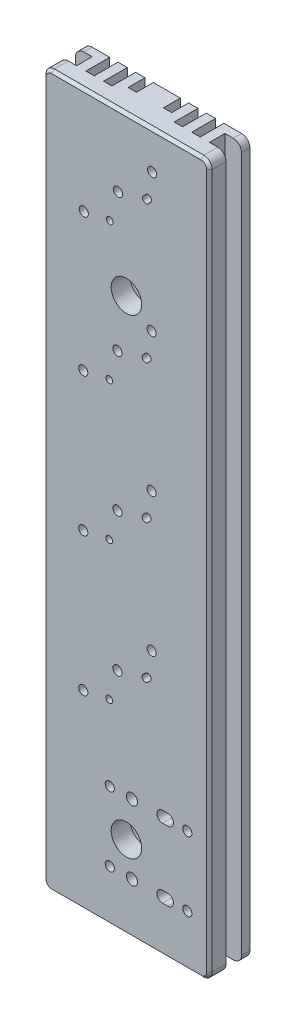
from build123d import *

# Parameters (mm, degrees)
SKETCH_1_W                  = 60
SKETCH_1_H                  = 260
EXTRUDE_1_DEPTH             = 14.6
MM_6_D                      = 2.4
MM_6_DEPTH                  = 5
MM_6_TIP                    = 0.721032743
CUT_EXTRUDE_1_DEPTH         = 5
HOLE_WIZARD_M4_1_D          = 3.3
HOLE_WIZARD_M4_1_DEPTH      = 5
HOLE_WIZARD_M4_1_TIP        = 0.991420021
HOLE_WIZARD_M4_2_AT_2_COUNT = 2
HOLE_WIZARD_M4_2_AT_2_PITCH = 27.999757981
CUT_EXTRUDE_2_DEPTH         = 5
SKETCH_19_W                 = 3
SKETCH_19_H                 = 260
CUT_EXTRUDE_3_DEPTH         = 8.6
PATTERN_LINEAR_2_COUNT      = 9
PATTERN_LINEAR_2_PITCH      = 6.375
FILLET_1_R                  = 1
HOLE_WIZARD_M4_4_D          = 3.3
HOLE_WIZARD_M4_4_DEPTH      = 5
HOLE_WIZARD_M4_4_TIP        = 0.991420021
MM_6_2_D                    = 2.4
MM_6_2_DEPTH                = 5
MM_6_2_TIP                  = 0.721032743
CUT_EXTRUDE_5_DEPTH         = 5
CHAMFER_2_SIZE              = 0.5
SKETCH_36_W                 = 6
SKETCH_36_H                 = 8.6
CUT_EXTRUDE_6_DEPTH         = 261
SKETCH_37_W                 = 6
SKETCH_37_H                 = 3
EXTRUDE_3_DEPTH             = 260
SKETCH_41_W                 = 3
SKETCH_41_H                 = 2.5
EXTRUDE_4_DEPTH             = 260
HOLE_WIZARD_3_D             = 6.6
HOLE_WIZARD_3_CBORE_D       = 11
HOLE_WIZARD_3_CBORE_DEPTH   = 6.8
PATTERN_LINEAR_3_COUNT      = 2
PATTERN_LINEAR_3_PITCH      = 25
MM_6_3_D                    = 4
MM_6_3_DEPTH                = 5
MM_6_3_TIP                  = 1.201721238
SKETCH_45_W                 = 60
SKETCH_45_H                 = 3
CUT_EXTRUDE_7_DEPTH         = 15.6
FILLET_2_R                  = 3
CHAMFER_5_SIZE              = 1
CUT_EXTRUDE_8_DEPTH         = 5


with BuildPart() as part:
    # 草图1 → 凸台-拉伸1 (new body)
    with BuildSketch(Plane.XY):
        with Locations((-1370.803187494, -284.67131833)):
            Rectangle(SKETCH_1_W, SKETCH_1_H)
    extrude(amount=EXTRUDE_1_DEPTH)

    # mm _6
    with Locations(Plane(origin=(-1376.81028397, -194.132502963, 14.6), x_dir=(1, 0, 0), z_dir=(0, 0, 1))):
        with Locations((0, 0)):
            Hole(MM_6_D / 2, depth=MM_6_DEPTH)
            with Locations((0, 0, -(MM_6_DEPTH + MM_6_TIP / 2))):  # 118° drill point
                Cone(0, MM_6_D / 2, MM_6_TIP, mode=Mode.SUBTRACT)

    # 草图13 → 切除-拉伸1 (cut)
    with BuildSketch(Plane.XY.offset(14.6)):
        with BuildLine():
            Line((-1362.067107582, -181.08638285), (-1362.91563572, -181.934910987))
            ThreePointArc((-1362.91563572, -181.934910987), (-1364.612691995, -181.934910987), (-1364.612691995, -180.237854712))
            Line((-1364.612691995, -180.237854712), (-1363.764163857, -179.389326575))
            ThreePointArc((-1363.764163857, -179.389326575), (-1362.067107582, -179.389326575), (-1362.067107582, -181.08638285))
        make_face()
    extrude(amount=-CUT_EXTRUDE_1_DEPTH, mode=Mode.SUBTRACT)

    # M4 螺纹孔1
    with Locations(Plane(origin=(-1386.194651617, -195.973455467, 14.6), x_dir=(1, 0, 0), z_dir=(0, 0, 1))):
        with Locations((0, 0), (12.347852167, 12.347852166), (24.695704333, 24.695704332)):
            Hole(HOLE_WIZARD_M4_1_D / 2, depth=HOLE_WIZARD_M4_1_DEPTH)
            with Locations((0, 0, -(HOLE_WIZARD_M4_1_DEPTH + HOLE_WIZARD_M4_1_TIP / 2))):  # 118° drill point
                Cone(0, HOLE_WIZARD_M4_1_D / 2, HOLE_WIZARD_M4_1_TIP, mode=Mode.SUBTRACT)

    # 草图16 → M4 螺纹孔2 (revolve, cut)
    with BuildSketch(Plane(origin=(-1376.802945467, -396.07039616, 14.6), x_dir=(0, -1, 0), z_dir=(1, 0, 0))):
        Polygon((0, 0), (0, 5.991420021), (1.65, 5), (1.65, 0), align=None)
    hole_wizard_m4_2 = revolve(axis=Axis((-1376.802945467, -396.07039616, 20.95), (0, 0, -1)), mode=Mode.SUBTRACT)

    # M4 螺纹孔2 at 2: M4 螺纹孔2 ×2
    with Locations(*[(i * HOLE_WIZARD_M4_2_AT_2_PITCH, 0, 0) for i in range(1, HOLE_WIZARD_M4_2_AT_2_COUNT)]):
        add(hole_wizard_m4_2, mode=Mode.SUBTRACT)

    # 草图17 → 切除-拉伸2 (cut)
    with BuildSketch(Plane.XY.offset(14.6)):
        with BuildLine():
            Line((-1357.803235908, -394.069936206), (-1355.803235909, -394.069887789))
            ThreePointArc((-1355.803235909, -394.069887789), (-1353.803187493, -396.069839372), (-1355.803139075, -398.069887788))
            Line((-1355.803139075, -398.069887788), (-1357.803139075, -398.069936205))
            ThreePointArc((-1357.803139075, -398.069936205), (-1359.803187491, -396.069984623), (-1357.803235908, -394.069936206))
        make_face()
    cut_extrude_2 = extrude(amount=-CUT_EXTRUDE_2_DEPTH, mode=Mode.SUBTRACT)

    # 草图18 → 大小mm 暗销孔3 (revolve, cut)
    with BuildSketch(Plane(origin=(-1368.802945469, -396.070202492, 14.6), x_dir=(0, -1, 0), z_dir=(1, 0, 0))):
        Polygon((0, 0), (0, 6.201721238), (2, 5), (2, 0), align=None)
    mm_3 = revolve(axis=Axis((-1368.802945469, -396.070202492, 20.95), (0, 0, -1)), mode=Mode.SUBTRACT)

    # 草图19 → 切除-拉伸3 (cut)
    with BuildSketch(Plane(origin=(0, 0, 0), x_dir=(-1, 0, 0), z_dir=(0, 0, -1))):
        with Locations((1345.303187494, -284.67131833)):
            Rectangle(SKETCH_19_W, SKETCH_19_H)
    cut_extrude_3 = extrude(amount=-CUT_EXTRUDE_3_DEPTH, mode=Mode.SUBTRACT)

    # 阵列(线性)2: 切除-拉伸3 ×9, 1 skipped
    with Locations(*[(-i * PATTERN_LINEAR_2_PITCH, 0, 0) for i in range(1, PATTERN_LINEAR_2_COUNT) if i not in (4,)]):
        add(cut_extrude_3, mode=Mode.SUBTRACT)

    # 圆角1
    fillet_1_edges = [part.edges().sort_by_distance(p)[0] for p in [
        (-1400.803187494, -154.67131833, 7.3),
    ]]
    fillet(fillet_1_edges, radius=FILLET_1_R)

    # M4 螺纹孔4
    with Locations(Plane(origin=(-1361.678552406, -321.098146012, 14.6), x_dir=(1, 0, 0), z_dir=(0, 0, 1))):
        with Locations((0, 0), (-12.347852167, -12.347852167), (-24.695704333, -24.695704333), (-24.695704333, 25.304295667), (-12.347852167, 37.652147833), (0, 50), (0, 100), (-12.347852167, 87.652147833), (-24.695704333, 75.304295667)):
            Hole(HOLE_WIZARD_M4_4_D / 2, depth=HOLE_WIZARD_M4_4_DEPTH)
            with Locations((0, 0, -(HOLE_WIZARD_M4_4_DEPTH + HOLE_WIZARD_M4_4_TIP / 2))):  # 118° drill point
                Cone(0, HOLE_WIZARD_M4_4_D / 2, HOLE_WIZARD_M4_4_TIP, mode=Mode.SUBTRACT)

    # mm _6 2
    with Locations(Plane(origin=(-1376.989889093, -243.95289784, 14.6), x_dir=(1, 0, 0), z_dir=(0, 0, 1))):
        with Locations((0, 0), (0, -50), (0, -100)):
            Hole(MM_6_2_D / 2, depth=MM_6_2_DEPTH)
            with Locations((0, 0, -(MM_6_2_DEPTH + MM_6_2_TIP / 2))):  # 118° drill point
                Cone(0, MM_6_2_D / 2, MM_6_2_TIP, mode=Mode.SUBTRACT)

    # 草图35 → 切除-拉伸5 (cut)
    with BuildSketch(Plane.XY.offset(14.6)):
        with BuildLine():
            Line((-1362.246712705, -230.906777727), (-1363.095240842, -231.755305865))
            ThreePointArc((-1363.095240842, -231.755305865), (-1364.792297117, -231.755305865), (-1364.792297117, -230.05824959))
            Line((-1364.792297117, -230.05824959), (-1363.94376898, -229.209721453))
            ThreePointArc((-1363.94376898, -229.209721453), (-1362.246712705, -229.209721453), (-1362.246712705, -230.906777727))
        make_face()
        with BuildLine():
            Line((-1362.246712705, -280.906777727), (-1363.095240842, -281.755305865))
            ThreePointArc((-1363.095240842, -281.755305865), (-1364.792297117, -281.755305865), (-1364.792297117, -280.05824959))
            Line((-1364.792297117, -280.05824959), (-1363.94376898, -279.209721453))
            ThreePointArc((-1363.94376898, -279.209721453), (-1362.246712705, -279.209721453), (-1362.246712705, -280.906777727))
        make_face()
        with BuildLine():
            Line((-1362.246712705, -330.906777727), (-1363.095240842, -331.755305865))
            ThreePointArc((-1363.095240842, -331.755305865), (-1364.792297117, -331.755305865), (-1364.792297117, -330.05824959))
            Line((-1364.792297117, -330.05824959), (-1363.94376898, -329.209721453))
            ThreePointArc((-1363.94376898, -329.209721453), (-1362.246712705, -329.209721453), (-1362.246712705, -330.906777727))
        make_face()
    extrude(amount=-CUT_EXTRUDE_5_DEPTH, mode=Mode.SUBTRACT)

    # 倒角2
    chamfer_2_edges = [part.edges().sort_by_distance(p)[0] for p in [
        (-1393.115687494, -154.67131833, 0),
    ]]
    chamfer(chamfer_2_edges, length=CHAMFER_2_SIZE)

    # 草图36 → 切除-拉伸6 (cut, through all)
    with BuildSketch(Plane.XZ.offset(414.67131833)):
        with Locations((-1397.803187494, 4.3)):
            Rectangle(SKETCH_36_W, SKETCH_36_H)
        with Locations((-1343.803187494, 4.3)):
            Rectangle(SKETCH_36_W, SKETCH_36_H)
    extrude(amount=-CUT_EXTRUDE_6_DEPTH, mode=Mode.SUBTRACT)

    # 草图37 → 凸台-拉伸3 (add, through all)
    with BuildSketch(Plane.XZ.offset(414.67131833)):
        with Locations((-1397.803187494, 1.5)):
            Rectangle(SKETCH_37_W, SKETCH_37_H)
        with Locations((-1343.803187494, 1.5)):
            Rectangle(SKETCH_37_W, SKETCH_37_H)
    extrude(amount=-EXTRUDE_3_DEPTH)

    # 草图41 → 凸台-拉伸4 (add, through all)
    with BuildSketch(Plane(origin=(0, -154.67131833, 0), x_dir=(1, 0, 0), z_dir=(0, 1, 0))):
        with Locations((-1377.178187494, -7.35)):
            Rectangle(SKETCH_41_W, SKETCH_41_H)
        with Locations((-1364.428187494, -7.35)):
            Rectangle(SKETCH_41_W, SKETCH_41_H)
    extrude(amount=-EXTRUDE_4_DEPTH)

    # 打孔尺寸(%根据)内六角圆柱头螺钉的类型3 (through all)
    with Locations(Plane(origin=(-1370.803187494, -384.67131833, 14.6), x_dir=(1, 0, 0), z_dir=(0, 0, 1))):
        with Locations((0, 0), (0, 170)):
            CounterBoreHole(HOLE_WIZARD_3_D / 2, HOLE_WIZARD_3_CBORE_D / 2, HOLE_WIZARD_3_CBORE_DEPTH)

    # 阵列(线性)3: M4 螺纹孔2, 切除-拉伸2, 大小mm 暗销孔3 ×2
    with Locations(*[(0, i * PATTERN_LINEAR_3_PITCH, 0) for i in range(1, PATTERN_LINEAR_3_COUNT)]):
        add(hole_wizard_m4_2, mode=Mode.SUBTRACT)
        add(cut_extrude_2, mode=Mode.SUBTRACT)
        add(mm_3, mode=Mode.SUBTRACT)

    # 阵列(线性)3 copy 1 sketch → 阵列(线性)3 copy 1 (revolve, cut)
    with BuildSketch(Plane(origin=(-1348.803187494, -371.06971833, 14.6), x_dir=(0, -1, 0), z_dir=(1, 0, 0))):
        Polygon((0, 0), (0, 5.991420021), (1.65, 5), (1.65, 0), align=None)
    revolve(axis=Axis((-1348.803187494, -371.06971833, 20.95), (0, 0, -1)), mode=Mode.SUBTRACT)

    # mm _6 3
    with Locations(Plane(origin=(-1370.803187494, -224.67131833, 0), x_dir=(-1, 0, 0), z_dir=(0, 0, -1))):
        with Locations((0, 0)):
            Hole(MM_6_3_D / 2, depth=MM_6_3_DEPTH)
            with Locations((0, 0, -(MM_6_3_DEPTH + MM_6_3_TIP / 2))):  # 118° drill point
                Cone(0, MM_6_3_D / 2, MM_6_3_TIP, mode=Mode.SUBTRACT)

    # 草图45 → 切除-拉伸7 (cut, through all)
    with BuildSketch(Plane.XY.offset(14.6)):
        with Locations((-1370.803187494, -156.17131833)):
            Rectangle(SKETCH_45_W, SKETCH_45_H)
    extrude(amount=-CUT_EXTRUDE_7_DEPTH, mode=Mode.SUBTRACT)

    # 圆角2
    fillet_2_edges = [part.edges().sort_by_distance(p)[0] for p in [
        (-1340.803187494, -414.67131833, 11.6),
        (-1400.803187494, -414.67131833, 1.5),
        (-1340.803187494, -414.67131833, 1.5),
        (-1400.803187494, -157.67131833, 11.6),
        (-1340.803187494, -157.67131833, 1.5),
        (-1340.803187494, -157.67131833, 11.6),
        (-1400.803187494, -157.67131833, 1.5),
        (-1400.803187494, -414.67131833, 11.6),
    ]]
    fillet(fillet_2_edges, radius=FILLET_2_R)

    # 倒角5
    chamfer_5_edges = [part.edges().sort_by_distance(p)[0] for p in [
        (-1370.803187494, -157.67131833, 14.6),
        (-1370.803187494, -414.67131833, 14.6),
        (-1340.803187494, -286.17131833, 14.6),
        (-1400.803187494, -286.17131833, 14.6),
        (-1399.924507838, -158.549997986, 14.6),
        (-1399.924507838, -413.792638673, 14.6),
        (-1341.681867151, -413.792638673, 14.6),
        (-1341.681867151, -158.549997986, 14.6),
    ]]
    chamfer(chamfer_5_edges, length=CHAMFER_5_SIZE)

    # 草图46 → 切除-拉伸8 (cut)
    with BuildSketch(Plane(origin=(0, 0, 0), x_dir=(-1, 0, 0), z_dir=(0, 0, -1))):
        with BuildLine():
            Line((1372.803187494, -373.67131833), (1372.803187494, -375.67131833))
            ThreePointArc((1372.803187494, -375.67131833), (1370.803187494, -377.67131833), (1368.803187494, -375.67131833))
            Line((1368.803187494, -375.67131833), (1368.803187494, -373.67131833))
            ThreePointArc((1368.803187494, -373.67131833), (1370.803187494, -371.67131833), (1372.803187494, -373.67131833))
        make_face()
    extrude(amount=-CUT_EXTRUDE_8_DEPTH, mode=Mode.SUBTRACT)


solid = part.part
